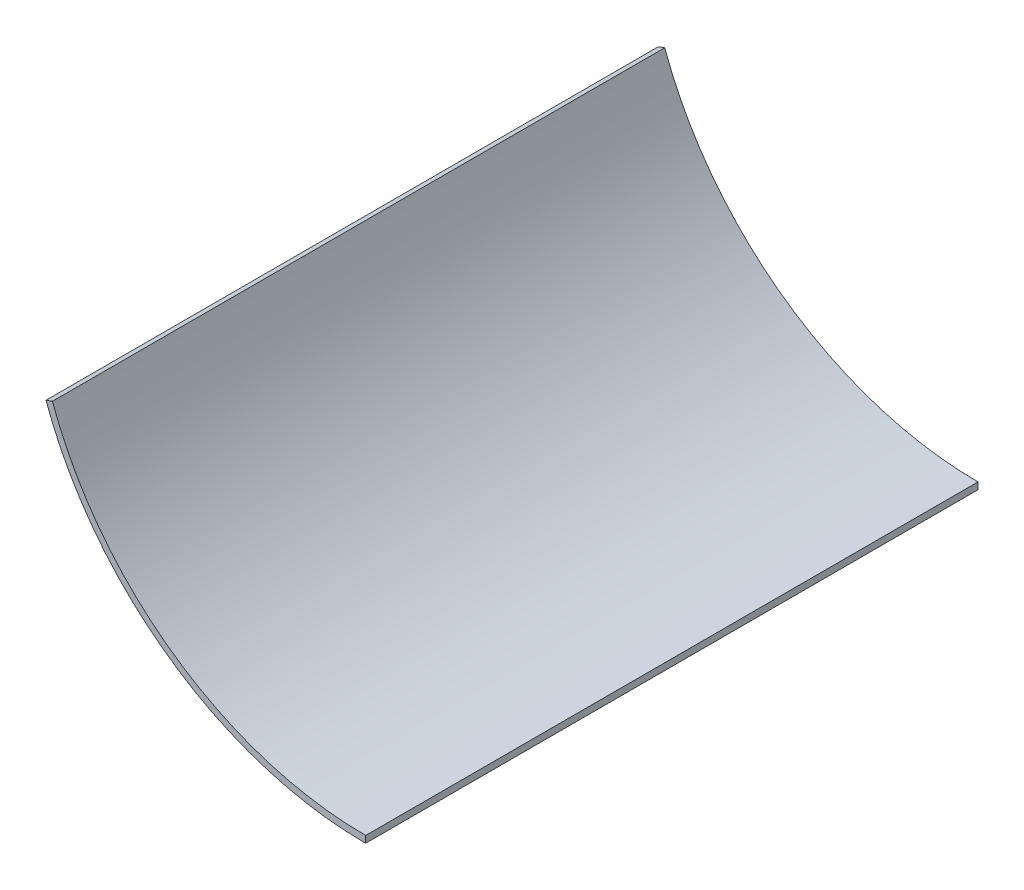
from build123d import *

# Parameters (mm, degrees)
DODANIE_WYCI_GNI_CIE1_DEPTH = 900


with BuildPart() as part:
    # Szkic1 → Dodanie-wyciągnięcie1 (new body)
    with BuildSketch(Plane.XY):
        with BuildLine():
            Line((-469.846310393, -171.010071663), (-460.449384185, -167.58987023))
            ThreePointArc((-460.449384185, -167.58987023), (-281.052453812, -401.384501702), (0, -490))
            Line((0, -490), (0, -500))
            ThreePointArc((0, -500), (-286.788218176, -409.576022144), (-469.846310393, -171.010071663))
        make_face()
    extrude(amount=DODANIE_WYCI_GNI_CIE1_DEPTH)


solid = part.part
